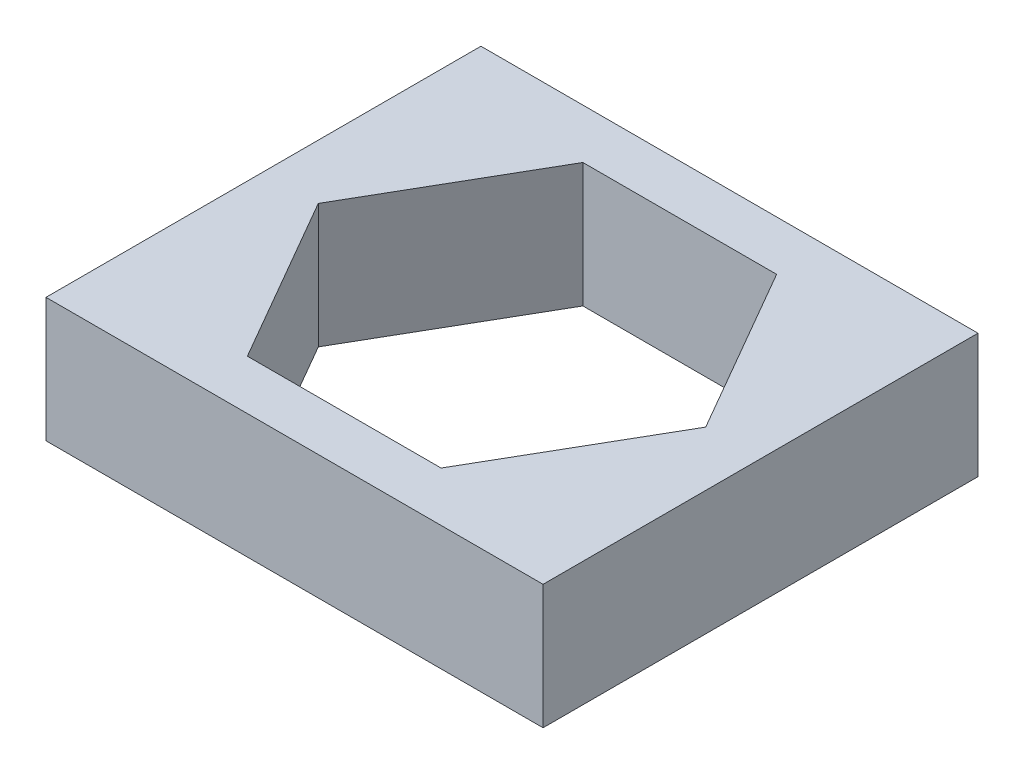
from build123d import *

# Parameters (mm, degrees)
SKETCH1_W           = 8
SKETCH1_H           = 7
BOSS_EXTRUDE1_DEPTH = 2


with BuildPart() as part:
    # Sketch1 → Boss-Extrude1 (new body)
    with BuildSketch(Plane(origin=(0, 0, 0), x_dir=(1, 0, 0), z_dir=(0, 1, 0))):
        with Locations((4, 3.5)):
            Rectangle(SKETCH1_W, SKETCH1_H)
        Polygon((7.117691454, 3.5), (5.558845727, 6.2), (2.441154273, 6.2), (0.882308546, 3.5), (2.441154273, 0.8), (5.558845727, 0.8), align=None, mode=Mode.SUBTRACT)
    extrude(amount=BOSS_EXTRUDE1_DEPTH)


solid = part.part
